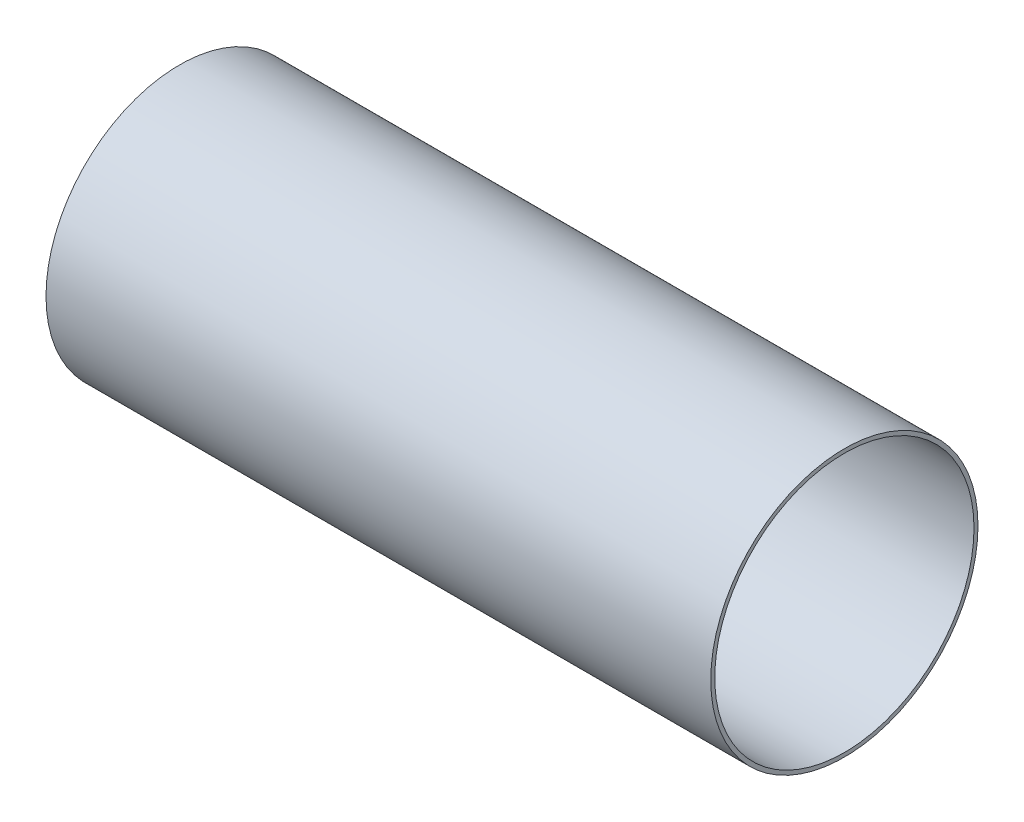
from build123d import *

# Parameters (mm, degrees)
SKETCH1_R                = 51.054
SKETCH1_R_2              = 49.53
BOSS_EXTRUDE1_DEPTH      = 127
BOSS_EXTRUDE1_DEPTH_BACK = 127


with BuildPart() as part:
    # Sketch1 → Boss-Extrude1 (new body, two sides)
    with BuildSketch(Plane.YZ) as boss_extrude1_sk:
        Circle(SKETCH1_R)
        Circle(SKETCH1_R_2, mode=Mode.SUBTRACT)
    extrude(amount=BOSS_EXTRUDE1_DEPTH)
    extrude(boss_extrude1_sk.sketch, amount=-BOSS_EXTRUDE1_DEPTH_BACK)


solid = part.part
